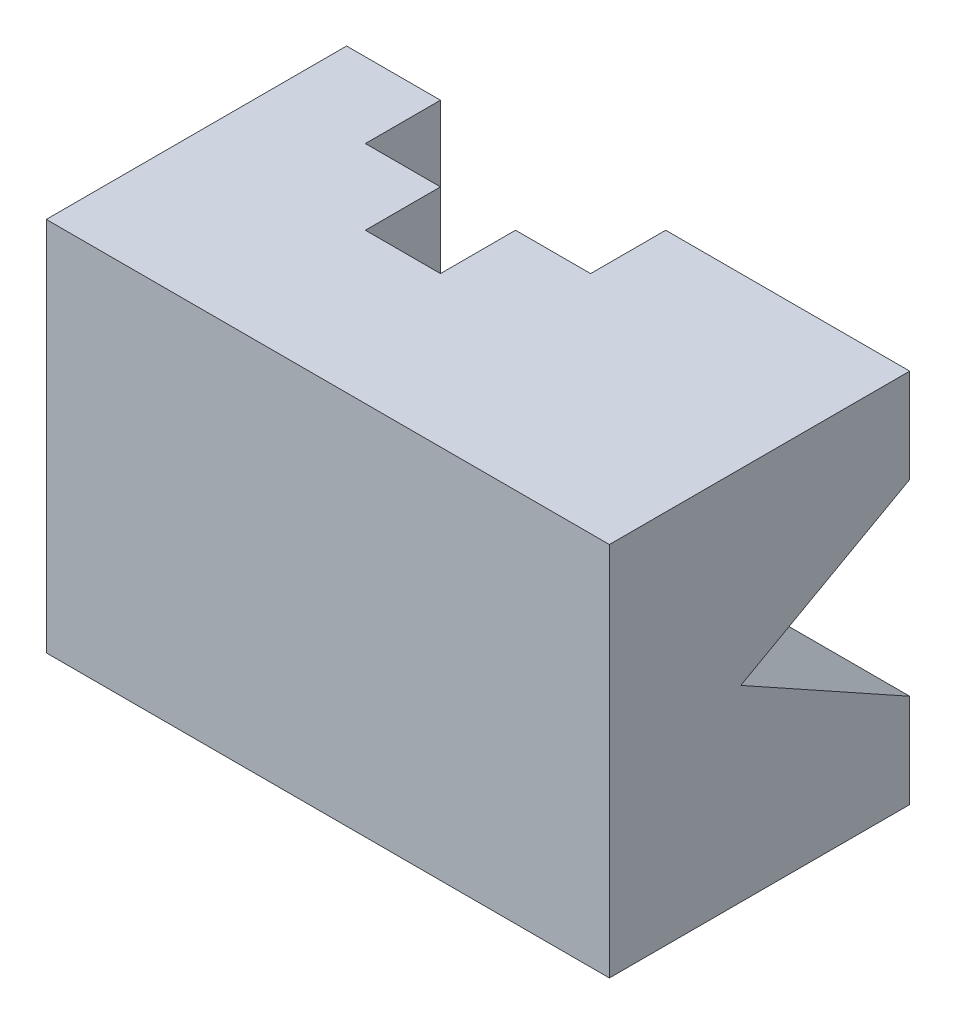
from build123d import *

# Parameters (mm, degrees)
BOSS_EXTRUDE1_DEPTH = 100
CUT_EXTRUDE2_DEPTH  = 50


with BuildPart() as part:
    # Sketch1 → Boss-Extrude1 (new body)
    with BuildSketch(Plane(origin=(0, 0, 0), x_dir=(1, 0, 0), z_dir=(0, 1, 0))):
        Polygon((-50, 20), (-50, 40), (-75, 40), (-75, -40), (75, -40), (75, 40), (10, 40), (10, 20), (-10, 20), (-10, 0), (-30, 0), (-30, 20), align=None)
    extrude(amount=BOSS_EXTRUDE1_DEPTH)

    # Sketch3 → Cut-Extrude2 (cut)
    with BuildSketch(Plane(origin=(75, 0, 0), x_dir=(0, 0, -1), z_dir=(1, 0, 0))):
        Polygon((40, 75), (-5, 50), (40, 25), align=None)
    extrude(amount=-CUT_EXTRUDE2_DEPTH, mode=Mode.SUBTRACT)


solid = part.part
